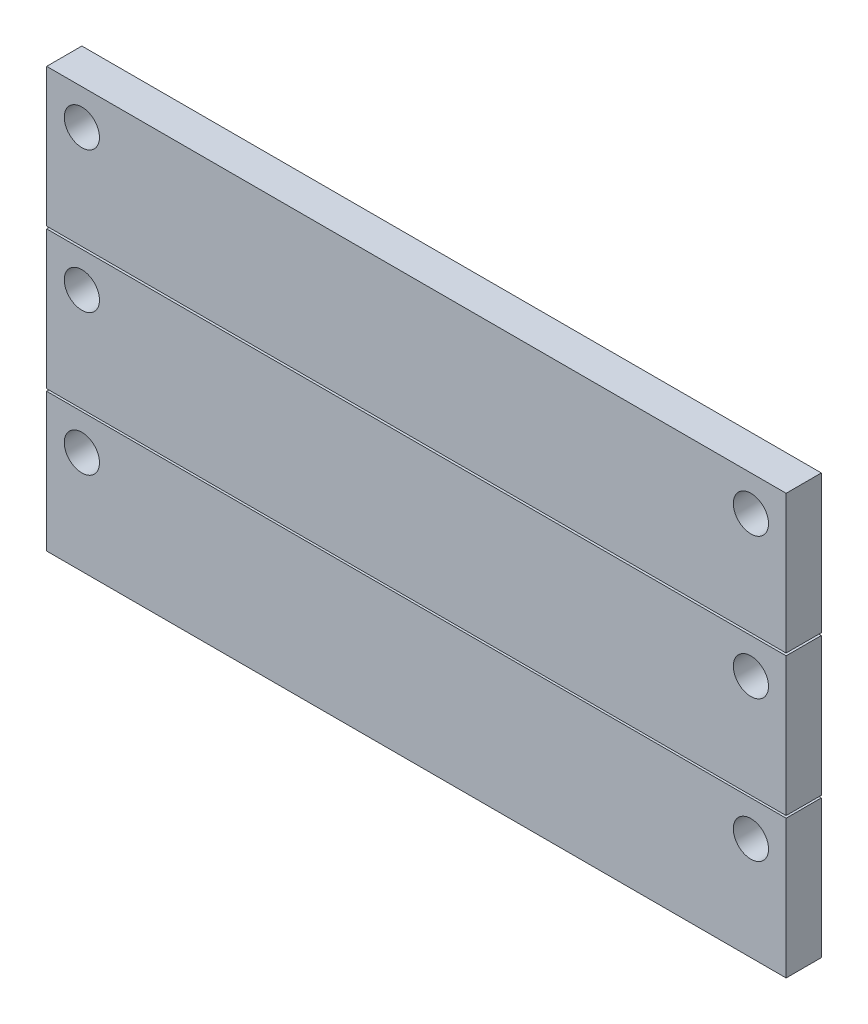
from build123d import *

# Parameters (mm, degrees)
SKETCH1_W             = 533.4
SKETCH1_H             = 99.822
BOSS_EXTRUDE1_DEPTH   = 25.4
BOSS_EXTRUDE1_2_DEPTH = 25.4
BOSS_EXTRUDE1_3_DEPTH = 25.4
SKETCH2_R             = 12.7
CUT_EXTRUDE1_DEPTH    = 26.4
LPATTERN1_COUNT       = 3
LPATTERN1_PITCH       = 101.6


with BuildPart() as part:
    # Sketch1 → Boss-Extrude1 (new body)
    with BuildSketch(Plane.XY):
        with Locations((-266.7, -49.911)):
            Rectangle(SKETCH1_W, SKETCH1_H)
    extrude(amount=BOSS_EXTRUDE1_DEPTH)


with BuildPart() as body_2:
    # Sketch1 → Boss-Extrude1 2 (new body)
    with BuildSketch(Plane.XY):
        with Locations((-266.7, 51.628691072)):
            Rectangle(SKETCH1_W, SKETCH1_H)
    extrude(amount=BOSS_EXTRUDE1_2_DEPTH)

    # Sketch2 → Cut-Extrude1 (cut, through all)
    with BuildSketch(Plane.XY.offset(25.4)):
        with Locations((-508, 76.139691072)):
            Circle(SKETCH2_R)
        with Locations((-25.4, 76.139691072)):
            Circle(SKETCH2_R)
    cut_extrude1 = extrude(amount=-CUT_EXTRUDE1_DEPTH, mode=Mode.SUBTRACT)


with BuildPart() as body_3:
    # Sketch1 → Boss-Extrude1 3 (new body)
    with BuildSketch(Plane.XY):
        with Locations((-266.7, -151.356836193)):
            Rectangle(SKETCH1_W, SKETCH1_H)
    extrude(amount=BOSS_EXTRUDE1_3_DEPTH)


with BuildPart() as lpattern1_tool:
    # LPattern1: Cut-Extrude1 ×3
    with Locations(*[(0, -i * LPATTERN1_PITCH, 0) for i in range(1, LPATTERN1_COUNT)]):
        add(cut_extrude1)


with BuildPart() as part_1:
    add(part.part)

    # LPattern1: cut by lpattern1_tool
    add(lpattern1_tool.part, mode=Mode.SUBTRACT)


with BuildPart() as body_3_1:
    add(body_3.part)

    # LPattern1: cut by lpattern1_tool
    add(lpattern1_tool.part, mode=Mode.SUBTRACT)


solid = Compound([body_2.part, part_1.part, body_3_1.part])
